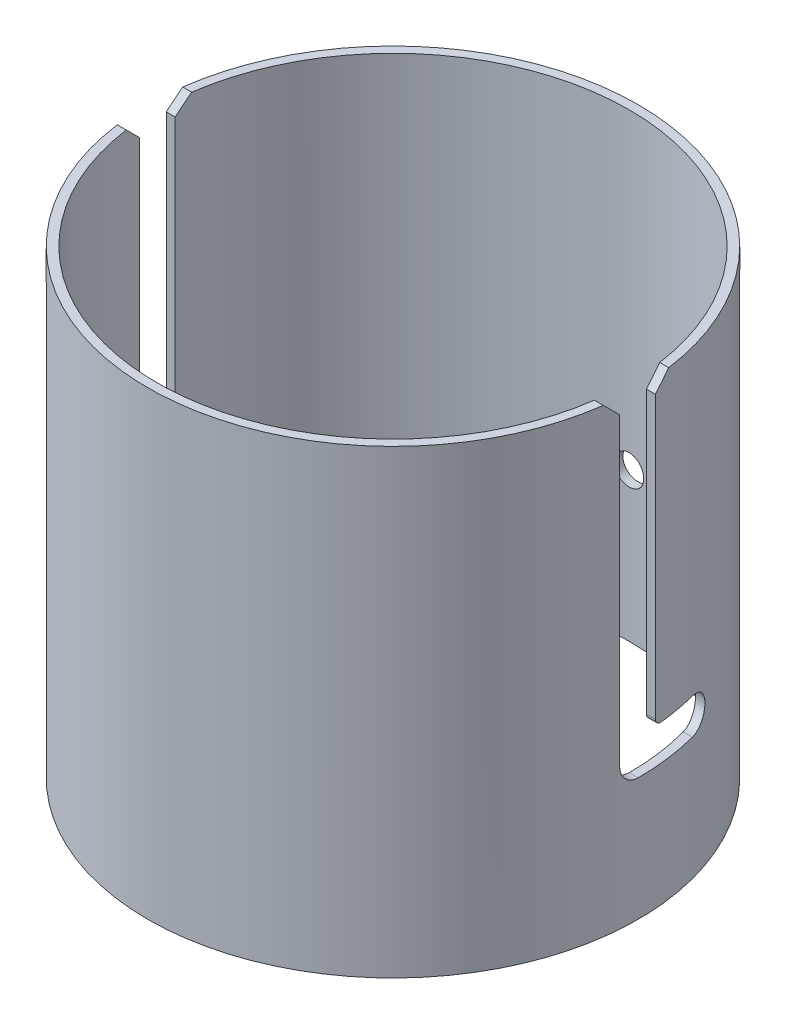
from build123d import *

# Parameters (mm, degrees)
SKETCH2_W                    = 3
SKETCH2_H                    = 155
CUT_EXTRUDE1_DEPTH           = 83.55
FILLET1_R                    = 6
CHAMFER1_SIZE                = 5
FILLET4_R                    = 2
CIRPATTERN1_COUNT            = 2
FILLET1_OF_CIRPATTERN1_R     = 6
CHAMFER1_OF_CIRPATTERN1_SIZE = 5
FILLET4_OF_CIRPATTERN1_R     = 2
SKETCH4_R                    = 5
CUT_EXTRUDE2_DEPTH           = 100


with BuildPart() as part:
    # Sketch2 → Revolve1 (revolve)
    with BuildSketch(Plane(origin=(0, 0, 0), x_dir=(0, 0, -1), z_dir=(1, 0, 0))):
        with Locations((-81.05, 77.5)):
            Rectangle(SKETCH2_W, SKETCH2_H)
    revolve(axis=Axis((0, -7.75, 0), (0, 1, 0)))

    # Sketch3 → Cut-Extrude1 (cut, through all)
    with BuildSketch(Plane(origin=(0, 0, 0), x_dir=(0, 0, -1), z_dir=(1, 0, 0))):
        with BuildLine():
            Line((-6, 155), (6, 155))
            Line((6, 155), (6, 41.3))
            Line((6, 41.3), (-21, 41.3))
            ThreePointArc((-21, 41.3), (-27, 47.3), (-21, 53.3))
            Line((-21, 53.3), (-6, 53.3))
            Line((-6, 53.3), (-6, 155))
        make_face()
    cut_extrude1 = extrude(amount=-CUT_EXTRUDE1_DEPTH, mode=Mode.SUBTRACT)

    # Fillet1
    fillet1_edges = [part.edges().sort_by_distance(p)[0] for p in [
        (-80.82753304, 41.3, -6),
    ]]
    fillet(fillet1_edges, radius=FILLET1_R)

    # Chamfer1
    chamfer1_edges = [part.edges().sort_by_distance(p)[0] for p in [
        (-80.82753304, 155, -6),
        (-80.82753304, 155, 6),
    ]]
    chamfer(chamfer1_edges, length=CHAMFER1_SIZE)

    # Fillet4
    fillet4_edges = [part.edges().sort_by_distance(p)[0] for p in [
        (-80.82753304, 53.3, 6),
    ]]
    fillet(fillet4_edges, radius=FILLET4_R)

    # CirPattern1: Cut-Extrude1 ×2 about axis
    cirpattern1_axis = Axis((0, -7.75, 0), (0, 1, 0))
    for i in range(1, CIRPATTERN1_COUNT):
        add(cut_extrude1.rotate(cirpattern1_axis, i * 360 / CIRPATTERN1_COUNT), mode=Mode.SUBTRACT)

    # Fillet1 of CirPattern1
    fillet1_of_cirpattern1_edges = [part.edges().sort_by_distance(p)[0] for p in [
        (80.82753304, 41.3, 6),
    ]]
    fillet(fillet1_of_cirpattern1_edges, radius=FILLET1_OF_CIRPATTERN1_R)

    # Chamfer1 of CirPattern1
    chamfer1_of_cirpattern1_edges = [part.edges().sort_by_distance(p)[0] for p in [
        (80.82753304, 155, 6),
        (80.82753304, 155, -6),
    ]]
    chamfer(chamfer1_of_cirpattern1_edges, length=CHAMFER1_OF_CIRPATTERN1_SIZE)

    # Fillet4 of CirPattern1
    fillet4_of_cirpattern1_edges = [part.edges().sort_by_distance(p)[0] for p in [
        (80.82753304, 53.3, -6),
    ]]
    fillet(fillet4_of_cirpattern1_edges, radius=FILLET4_OF_CIRPATTERN1_R)

    # Sketch4 → Cut-Extrude2 (cut)
    with BuildSketch(Plane.XY):
        with Locations((0, 50)):
            Circle(SKETCH4_R)
    extrude(amount=-CUT_EXTRUDE2_DEPTH, mode=Mode.SUBTRACT)


solid = part.part
